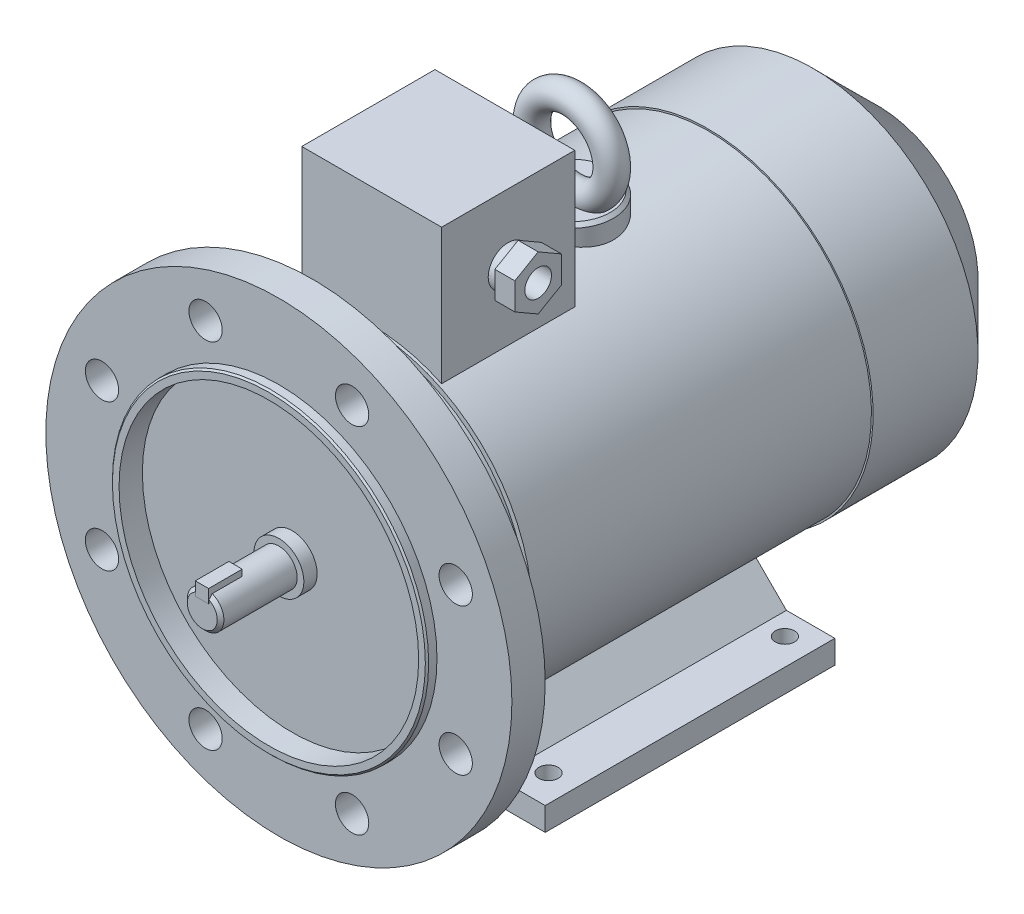
from build123d import *

# Parameters (mm, degrees)
SKETCH_1_R           = 5.5
EXTRUDE_1_DEPTH      = 23
SKETCH_2_W           = 4
SKETCH_2_H           = 4
EXTRUDE_2_DEPTH      = 0.1
EXTRUDE_2_DEPTH_BACK = 10
SKETCH_3_R           = 7.5
EXTRUDE_11_DEPTH     = 4
SKETCH_16_R          = 70
SKETCH_16_R_2        = 47.5
EXTRUDE_13_DEPTH     = 10
SKETCH_17_R          = 47.5
EXTRUDE_14_DEPTH     = 23
SKETCH_18_R          = 5
CUT_EXTRUDE_4_DEPTH  = 28
SKETCH_20_R          = 49
EXTRUDE_15_DEPTH     = 102
SKETCH_21_R          = 49.5
EXTRUDE_16_DEPTH     = 51
CHAMFER_3_SIZE       = 19.5
EXTRUDE_17_DEPTH     = 87
CUT_EXTRUDE_5_REACH  = 128
SKETCH_23_R          = 2.9
SKETCH_24_W          = 42
SKETCH_24_H          = 40
EXTRUDE_18_DEPTH     = 43
SKETCH_25_R          = 12.5
EXTRUDE_19_DEPTH     = 12
CHAMFER_4_SIZE       = 1
SKETCH_27_R          = 4
CHAMFER_5_SIZE       = 1
SKETCH_28_R          = 47.5
SKETCH_28_R_2        = 45
EXTRUDE_20_DEPTH     = 7
CHAMFER_6_SIZE       = 0.5
SKETCH_29_R          = 6
EXTRUDE_21_DEPTH     = 3
EXTRUDE_22_DEPTH     = 6
SKETCH_31_R          = 4
CUT_EXTRUDE_6_DEPTH  = 10


with BuildPart() as part:
    # Эскиз1 → Вытянуть1 (new body)
    with BuildSketch(Plane.XY):
        Circle(SKETCH_1_R)
    extrude(amount=EXTRUDE_1_DEPTH)

    # Эскиз2 → Вытянуть2 (add, two sides)
    with BuildSketch(Plane.XY.offset(23)) as extrude_2_sk:
        with Locations((0, 5)):
            Rectangle(SKETCH_2_W, SKETCH_2_H)
    extrude(amount=EXTRUDE_2_DEPTH)
    extrude(extrude_2_sk.sketch, amount=-EXTRUDE_2_DEPTH_BACK)

    # Эскиз3 → Вытянуть11 (add)
    with BuildSketch(Plane(origin=(0, 0, 0), x_dir=(-1, 0, 0), z_dir=(0, 0, -1))):
        Circle(SKETCH_3_R)
    extrude(amount=EXTRUDE_11_DEPTH)



with BuildPart() as body_2:
    # Эскиз16 → Вытянуть13 (new body)
    with BuildSketch(Plane.XY):
        Circle(SKETCH_16_R)
        Circle(SKETCH_16_R_2, mode=Mode.SUBTRACT)
    extrude(amount=-EXTRUDE_13_DEPTH)


with BuildPart() as part_1:
    add(part.part)

    add(body_2.part)  # Вытянуть14 merges body 2
    # Эскиз17 → Вытянуть14 (add)
    with BuildSketch(Plane(origin=(0, 0, -4), x_dir=(-1, 0, 0), z_dir=(0, 0, -1))):
        with Locations(Location((0, 0, 0), (0, 0, 180))):  # turned: the seam where the file's is
            Circle(SKETCH_17_R)
    extrude(amount=EXTRUDE_14_DEPTH)

    # Эскиз18 → Вырез-Вытянуть4 (cut, through all)
    with BuildSketch(Plane.XY):
        with Locations((-22.004297361, 53.123073119)):
            Circle(SKETCH_18_R)
        with Locations((22.004297361, 53.123073119)):
            Circle(SKETCH_18_R)
        with Locations((53.123073119, 22.004297361)):
            Circle(SKETCH_18_R)
        with Locations((53.123073119, -22.004297361)):
            Circle(SKETCH_18_R)
        with Locations((22.004297361, -53.123073119)):
            Circle(SKETCH_18_R)
        with Locations((-22.004297361, -53.123073119)):
            Circle(SKETCH_18_R)
        with Locations((-53.123073119, -22.004297361)):
            Circle(SKETCH_18_R)
        with Locations((-53.123073119, 22.004297361)):
            Circle(SKETCH_18_R)
    extrude(amount=-CUT_EXTRUDE_4_DEPTH, mode=Mode.SUBTRACT)

    # Эскиз20 → Вытянуть15 (add)
    with BuildSketch(Plane(origin=(0, 0, -27), x_dir=(-1, 0, 0), z_dir=(0, 0, -1))):
        Circle(SKETCH_20_R)
    extrude(amount=EXTRUDE_15_DEPTH)

    # Эскиз21 → Вытянуть16 (add)
    with BuildSketch(Plane(origin=(0, 0, -129), x_dir=(-1, 0, 0), z_dir=(0, 0, -1))):
        Circle(SKETCH_21_R)
    extrude(amount=EXTRUDE_16_DEPTH)

    # Фаска3
    chamfer_3_edges = [part_1.edges().sort_by_distance(p)[0] for p in [
        (49.5, 0, -180),
    ]]
    chamfer(chamfer_3_edges, length=CHAMFER_3_SIZE)

    # Эскиз22 → Вытянуть17 (add)
    with BuildSketch(Plane.XY.offset(-27)):
        with BuildLine():
            Line((-53, -49), (-53, -56))
            Line((-53, -56), (-44.904134404, -56))
            Line((-44.904134404, -56), (-42, -56))
            Line((-42, -56), (-32.646287703, -56))
            Line((-32.646287703, -56), (-20.944471698, -44.298183995))
            ThreePointArc((-20.944471698, -44.298183995), (-24.169591816, -42.624298603), (-27.261801405, -40.716018766))
            Line((-27.261801405, -40.716018766), (-35.54578264, -49))
            Line((-35.54578264, -49), (-53, -49))
        make_face()
        with BuildLine():
            Line((-26.179896787, -39.634114147), (-27.261801405, -40.716018766))
            ThreePointArc((-27.261801405, -40.716018766), (-24.169591816, -42.624298603), (-20.944471698, -44.298183995))
            Line((-20.944471698, -44.298183995), (-19.815619627, -43.169331924))
            ThreePointArc((-19.815619627, -43.169331924), (-23.065587435, -41.52383263), (-26.179896787, -39.634114147))
        make_face()
        with BuildLine():
            Line((-19.29701834, -32.7512357), (-26.179896787, -39.634114147))
            ThreePointArc((-26.179896787, -39.634114147), (-23.065587435, -41.52383263), (-19.815619627, -43.169331924))
            Line((-19.815619627, -43.169331924), (-14.172440123, -37.52615242))
            Line((-14.172440123, -37.52615242), (-19.29701834, -32.7512357))
        make_face()
        with BuildLine():
            ThreePointArc((28.971766908, -39.517549547), (25.460241586, -41.8661689), (21.759468274, -43.903593707))
            Line((21.759468274, -43.903593707), (33.855874567, -56))
            Line((33.855874567, -56), (42, -56))
            Line((42, -56), (43.639075317, -56))
            Line((43.639075317, -56), (53, -56))
            Line((53, -56), (53, -49))
            Line((53, -49), (38.45421736, -49))
            Line((38.45421736, -49), (28.971766908, -39.517549547))
        make_face()
        with BuildLine():
            Line((15.243541187, -37.38766662), (20.638100121, -42.782225554))
            ThreePointArc((20.638100121, -42.782225554), (24.364898956, -40.775013168), (27.89820479, -38.44398743))
            Line((27.89820479, -38.44398743), (25.07325078, -35.61903342))
            Line((25.07325078, -35.61903342), (15.243541187, -37.38766662))
        make_face()
    extrude(amount=-EXTRUDE_17_DEPTH)

    # Эскиз23 → Вырез-Вытянуть5 (cut, up to next)
    with BuildSketch(Plane.XZ.offset(56), mode=Mode.PRIVATE) as cut_extrude_5_sk1:
        with Locations(Location((45, -36, 0), (0, 0, 270))):  # turned: the seam where the file's is
            Circle(SKETCH_23_R)
    cut_extrude_5_tool1 = extrude(cut_extrude_5_sk1.sketch, amount=-CUT_EXTRUDE_5_REACH, mode=Mode.PRIVATE) & part_1.part
    add(cut_extrude_5_tool1.solids().sort_by_distance((45, -56, -36))[0], mode=Mode.SUBTRACT)
    # Эскиз23 → Вырез-Вытянуть5 (cut, up to next)
    with BuildSketch(Plane.XZ.offset(56), mode=Mode.PRIVATE) as cut_extrude_5_sk2:
        with Locations(Location((-45, -36, 0), (0, 0, 270))):  # turned: the seam where the file's is
            Circle(SKETCH_23_R)
    cut_extrude_5_tool2 = extrude(cut_extrude_5_sk2.sketch, amount=-CUT_EXTRUDE_5_REACH, mode=Mode.PRIVATE) & part_1.part
    add(cut_extrude_5_tool2.solids().sort_by_distance((-45, -56, -36))[0], mode=Mode.SUBTRACT)
    # Эскиз23 → Вырез-Вытянуть5 (cut, up to next)
    with BuildSketch(Plane.XZ.offset(56), mode=Mode.PRIVATE) as cut_extrude_5_sk3:
        with Locations(Location((45, -107, 0), (0, 0, 270))):  # turned: the seam where the file's is
            Circle(SKETCH_23_R)
    cut_extrude_5_tool3 = extrude(cut_extrude_5_sk3.sketch, amount=-CUT_EXTRUDE_5_REACH, mode=Mode.PRIVATE) & part_1.part
    add(cut_extrude_5_tool3.solids().sort_by_distance((45, -56, -107))[0], mode=Mode.SUBTRACT)
    # Эскиз23 → Вырез-Вытянуть5 (cut, up to next)
    with BuildSketch(Plane.XZ.offset(56), mode=Mode.PRIVATE) as cut_extrude_5_sk4:
        with Locations(Location((-45, -107, 0), (0, 0, 270))):  # turned: the seam where the file's is
            Circle(SKETCH_23_R)
    cut_extrude_5_tool4 = extrude(cut_extrude_5_sk4.sketch, amount=-CUT_EXTRUDE_5_REACH, mode=Mode.PRIVATE) & part_1.part
    add(cut_extrude_5_tool4.solids().sort_by_distance((-45, -56, -107))[0], mode=Mode.SUBTRACT)

    # Эскиз24 → Вытянуть18 (add)
    with BuildSketch(Plane(origin=(0, 42, 0), x_dir=(-1, 0, 0), z_dir=(0, 1, 0))):
        with Locations((0, -47.88562837)):
            Rectangle(SKETCH_24_W, SKETCH_24_H)
    extrude(amount=EXTRUDE_18_DEPTH)

    # Эскиз25 → Вытянуть19 (add)
    with BuildSketch(Plane(origin=(0, 42, 0), x_dir=(-1, 0, 0), z_dir=(0, 1, 0))):
        with Locations(Location((0, -88, 0), (0, 0, 270))):  # turned: the seam where the file's is
            Circle(SKETCH_25_R)
    extrude(amount=EXTRUDE_19_DEPTH)

    # Фаска4
    chamfer_4_edges = [part_1.edges().sort_by_distance(p)[0] for p in [
        (0, 54, -75.5),
    ]]
    chamfer(chamfer_4_edges, length=CHAMFER_4_SIZE)

    # По траектории1: sweep along a path in Эскиз26
    with BuildLine(Plane.XY.offset(-88)) as sweep_1_path:
        CenterArc((0, 66), 12, 0, 360)
    # Эскиз27 → По траектории1 (sweep)
    with BuildSketch(Plane(origin=(0, 0, 0), x_dir=(0, 0, -1), z_dir=(1, 0, 0))):
        with Locations((88, 78)):
            Circle(SKETCH_27_R)
    sweep(path=sweep_1_path.line)

    # Фаска5
    chamfer_5_edges = [part_1.edges().sort_by_distance(p)[0] for p in [
        (-3.102418411, -4.541475531, 23),
    ]]
    chamfer(chamfer_5_edges, length=CHAMFER_5_SIZE)

    # Эскиз28 → Вытянуть20 (add)
    with BuildSketch(Plane.XY.offset(-4)):
        Circle(SKETCH_28_R)
        Circle(SKETCH_28_R_2, mode=Mode.SUBTRACT)
    extrude(amount=EXTRUDE_20_DEPTH)

    # Фаска6
    chamfer_6_edges = [part_1.edges().sort_by_distance(p)[0] for p in [
        (-47.5, 0, 3),
    ]]
    chamfer(chamfer_6_edges, length=CHAMFER_6_SIZE)

    # Эскиз29 → Вытянуть21 (add)
    with BuildSketch(Plane(origin=(21, 0, 0), x_dir=(0, 0, -1), z_dir=(1, 0, 0))):
        with Locations(Location((47.88562837, 65, 0), (0, 0, 180))):  # turned: the seam where the file's is
            Circle(SKETCH_29_R)
    extrude(amount=EXTRUDE_21_DEPTH)

    # Эскиз30 → Вытянуть22 (add)
    with BuildSketch(Plane(origin=(24, 0, 0), x_dir=(0, 0, -1), z_dir=(1, 0, 0))):
        Polygon((47.88562837, 73.082903769), (40.88562837, 69.041451884), (40.88562837, 60.958548116), (47.88562837, 56.917096231), (54.88562837, 60.958548116), (54.88562837, 69.041451884), align=None)
    extrude(amount=EXTRUDE_22_DEPTH)

    # Эскиз31 → Вырез-Вытянуть6 (cut)
    with BuildSketch(Plane(origin=(30, 0, 0), x_dir=(0, 0, -1), z_dir=(1, 0, 0))):
        with Locations((47.88562837, 65)):
            Circle(SKETCH_31_R)
    extrude(amount=-CUT_EXTRUDE_6_DEPTH, mode=Mode.SUBTRACT)


solid = part_1.part
